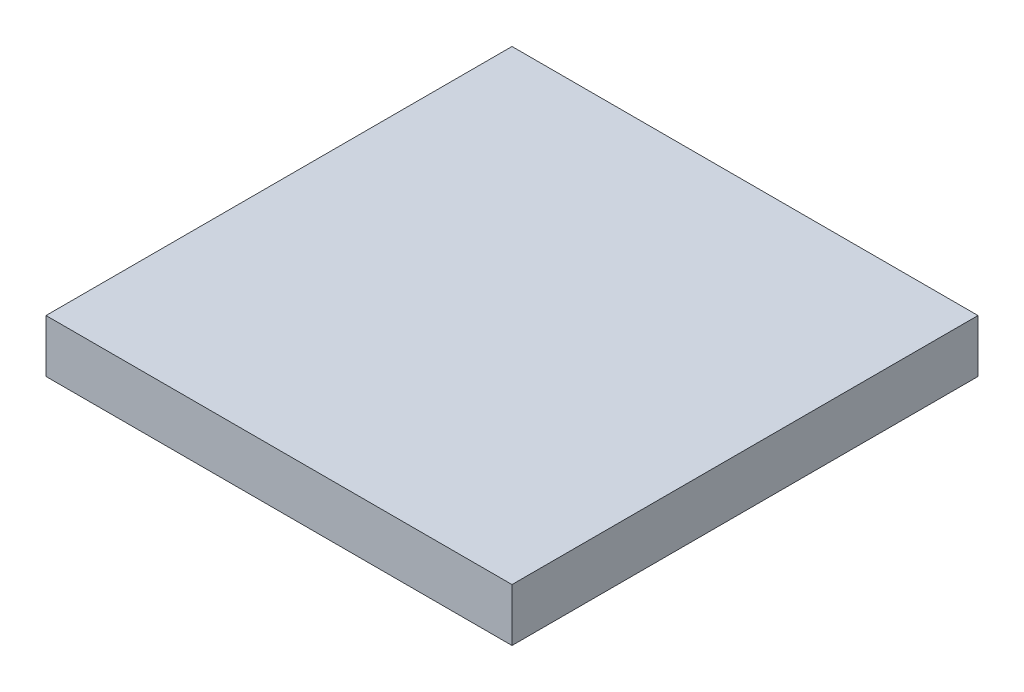
from build123d import *

# Parameters (mm, degrees)
SKETCH1_W           = 1.5
SKETCH1_H           = 1.5
BOSS_EXTRUDE1_DEPTH = 0.17


with BuildPart() as part:
    # Sketch1 → Boss-Extrude1 (new body)
    with BuildSketch(Plane(origin=(0, 0, 0), x_dir=(1, 0, 0), z_dir=(0, 1, 0))):
        with Locations((0.058695652, -0.039130435)):
            Rectangle(SKETCH1_W, SKETCH1_H)
    extrude(amount=BOSS_EXTRUDE1_DEPTH)


solid = part.part
